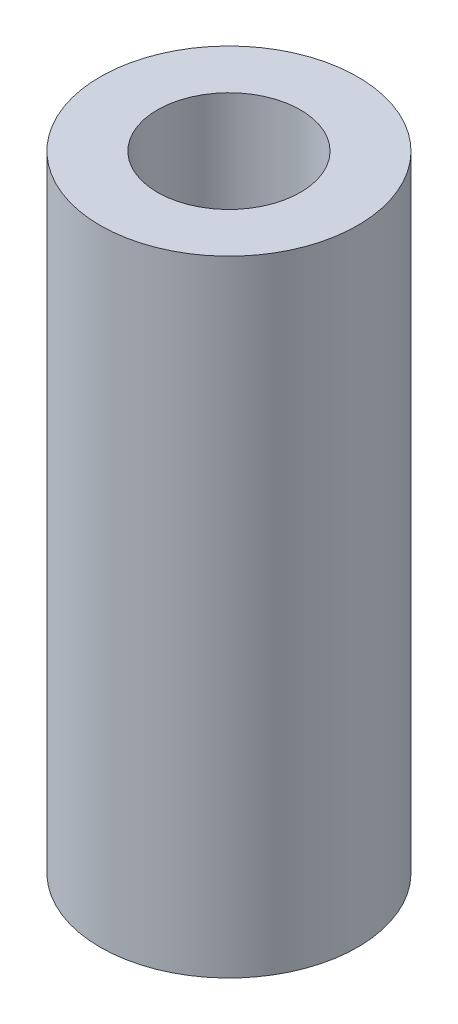
from build123d import *

# Parameters (mm, degrees)
SKETCH1_R           = 4.5
SKETCH1_R_2         = 2.5
BOSS_EXTRUDE1_DEPTH = 21.85


with BuildPart() as part:
    # Sketch1 → Boss-Extrude1 (new body)
    with BuildSketch(Plane(origin=(0, 0, 0), x_dir=(1, 0, 0), z_dir=(0, 1, 0))):
        Circle(SKETCH1_R)
        Circle(SKETCH1_R_2, mode=Mode.SUBTRACT)
    extrude(amount=BOSS_EXTRUDE1_DEPTH)


solid = part.part
